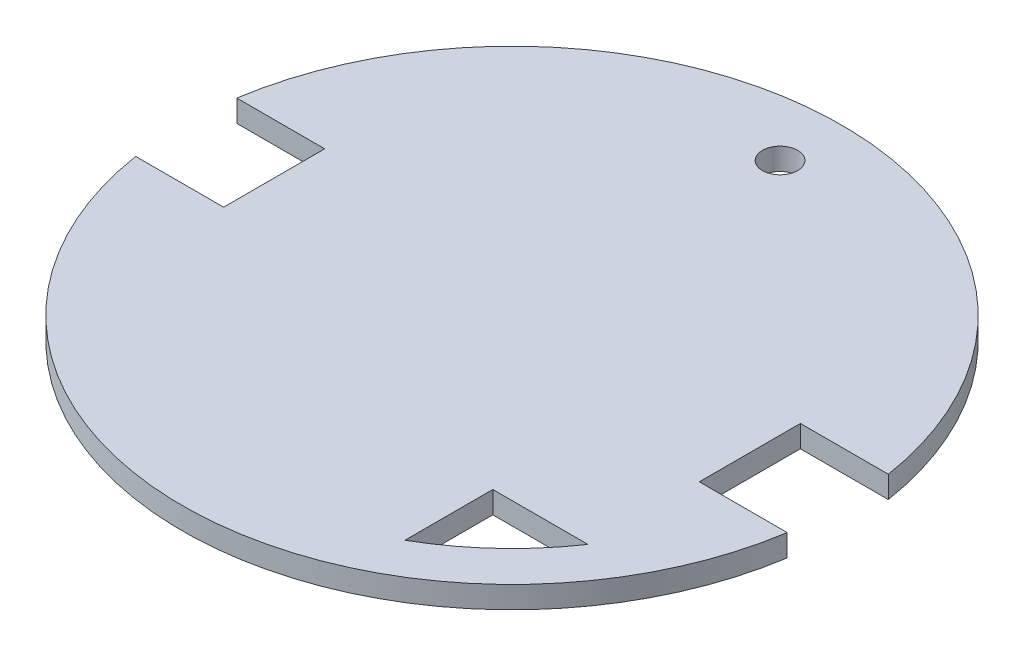
from build123d import *

# Parameters (mm, degrees)
SKETCH1_R           = 75
BOSS_EXTRUDE1_DEPTH = 5
SKETCH2_R           = 4
CUT_EXTRUDE1_DEPTH  = 5


with BuildPart() as part:
    # Sketch1 → Boss-Extrude1 (new body)
    with BuildSketch(Plane(origin=(0, 0, 0), x_dir=(1, 0, 0), z_dir=(0, 1, 0))):
        with Locations((-5.935816789, 0)):
            Circle(SKETCH1_R)
    extrude(amount=BOSS_EXTRUDE1_DEPTH)

    # Sketch2 → Cut-Extrude1 (cut)
    with BuildSketch(Plane(origin=(0, 5, 0), x_dir=(1, 0, 0), z_dir=(0, 1, 0))):
        with BuildLine():
            ThreePointArc((-80.048906052, -11.5), (-80.935816789, 0), (-80.048906052, 11.5))
            Line((-80.048906052, 11.5), (-89.004044114, 11.5))
            Line((-89.004044114, 11.5), (-89.004044114, -11.5))
            Line((-89.004044114, -11.5), (-80.048906052, -11.5))
        make_face()
        with BuildLine():
            Line((-69.910421126, 11.5), (-80.048906052, 11.5))
            Line((-80.048906052, 11.5), (-80.048906052, -11.5))
            Line((-80.048906052, -11.5), (-69.910421126, -11.5))
            ThreePointArc((-69.910421126, -11.5), (-70.935816789, 0), (-69.910421126, 11.5))
        make_face()
        with BuildLine():
            Line((-60.048906052, 11.5), (-69.910421126, 11.5))
            ThreePointArc((-69.910421126, 11.5), (-70.935816789, 0), (-69.910421126, -11.5))
            Line((-69.910421126, -11.5), (-60.048906052, -11.5))
            Line((-60.048906052, -11.5), (-60.048906052, 11.5))
        make_face()
        with BuildLine():
            ThreePointArc((59.064183211, 0), (58.807326793, 5.772812059), (58.038787547, 11.5))
            Line((58.038787547, 11.5), (48.177272473, 11.5))
            Line((48.177272473, 11.5), (48.177272473, -11.5))
            Line((48.177272473, -11.5), (58.038787547, -11.5))
            ThreePointArc((58.038787547, -11.5), (58.807326793, -5.772812059), (59.064183211, 0))
        make_face()
        with BuildLine():
            Line((68.177272473, -11.5), (68.177272473, 11.5))
            Line((68.177272473, 11.5), (58.038787547, 11.5))
            ThreePointArc((58.038787547, 11.5), (58.807326793, 5.772812059), (59.064183211, 0))
            ThreePointArc((59.064183211, 0), (58.807326793, -5.772812059), (58.038787547, -11.5))
            Line((58.038787547, -11.5), (68.177272473, -11.5))
        make_face()
        with BuildLine():
            Line((83.116270972, 11.5), (68.177272473, 11.5))
            ThreePointArc((68.177272473, 11.5), (68.842126799, 5.767074879), (69.064183211, 0))
            ThreePointArc((69.064183211, 0), (68.842126799, -5.767074879), (68.177272473, -11.5))
            Line((68.177272473, -11.5), (83.116270972, -11.5))
            Line((83.116270972, -11.5), (83.116270972, 11.5))
        make_face()
        with BuildLine():
            Line((26.200611139, -36.5), (26.200611139, -56.5))
            ThreePointArc((26.200611139, -56.5), (38.173054222, -47.743140849), (47.848474598, -36.5))
            Line((47.848474598, -36.5), (26.200611139, -36.5))
        make_face()
        with Locations((-5.948906052, 60.999998596)):
            Circle(SKETCH2_R)
        with BuildLine():
            Line((-80.048906052, -11.5), (-80.048906052, 11.5))
            ThreePointArc((-80.048906052, 11.5), (-80.935816789, 0), (-80.048906052, -11.5))
        make_face()
        with BuildLine():
            ThreePointArc((69.064183211, 0), (68.842126799, 5.767074879), (68.177272473, 11.5))
            Line((68.177272473, 11.5), (68.177272473, -11.5))
            ThreePointArc((68.177272473, -11.5), (68.842126799, -5.767074879), (69.064183211, 0))
        make_face()
    extrude(amount=-CUT_EXTRUDE1_DEPTH, mode=Mode.SUBTRACT)


solid = part.part
